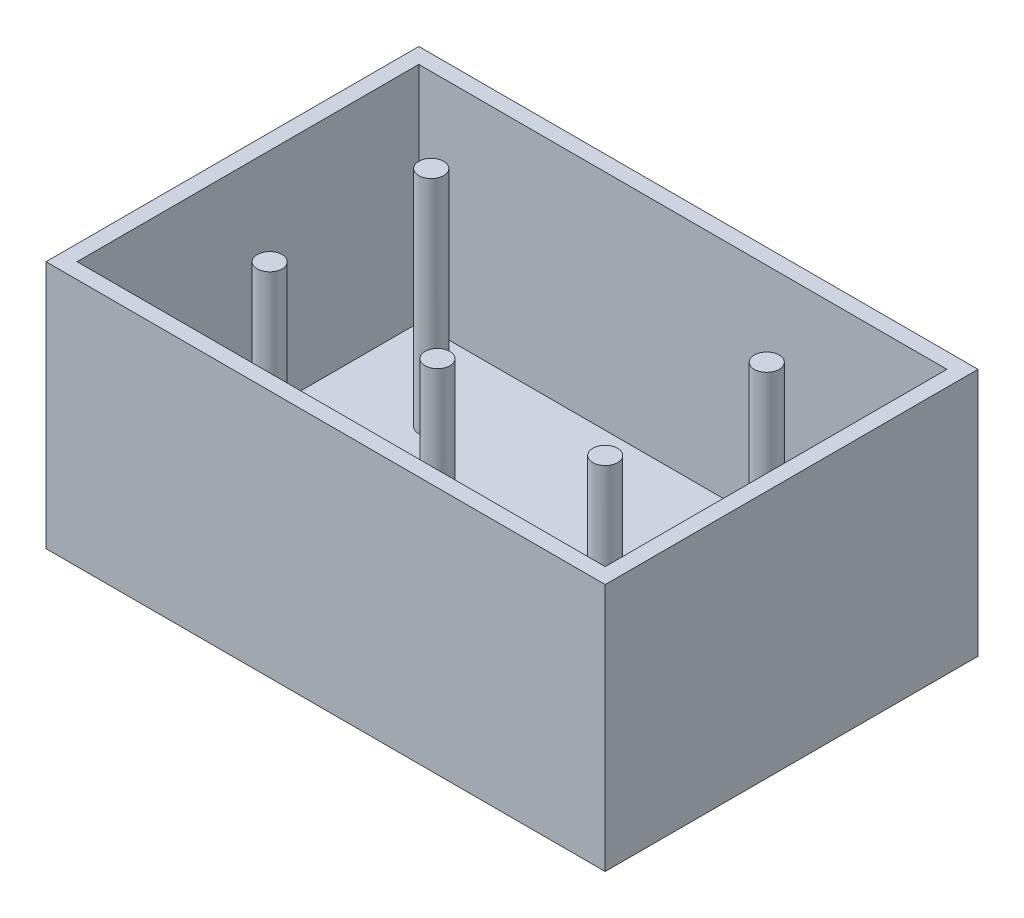
from build123d import *

# Parameters (mm, degrees)
SKETCH4_W           = 114.3
SKETCH4_H           = 76.2
BOSS_EXTRUDE2_DEPTH = 25.4
CUT_EXTRUDE1_REACH  = 47.72
SKETCH5_W           = 107.95
SKETCH5_H           = 69.85
SKETCH6_R           = 2.54
BOSS_EXTRUDE3_DEPTH = 25.4


with BuildPart() as part:
    # Sketch4 → Boss-Extrude2 (new body, symmetric)
    with BuildSketch(Plane(origin=(0, 0, 0), x_dir=(1, 0, 0), z_dir=(0, 1, 0))):
        Rectangle(SKETCH4_W, SKETCH4_H)
    extrude(amount=BOSS_EXTRUDE2_DEPTH, both=True)

    # Sketch5 → Cut-Extrude1 (cut, up to next)
    with BuildSketch(Plane(origin=(0, -20.32, 0), x_dir=(-1, 0, 0), z_dir=(0, -1, 0)), mode=Mode.PRIVATE) as cut_extrude1_sk1:
        Rectangle(SKETCH5_W, SKETCH5_H)
    cut_extrude1_tool1 = extrude(cut_extrude1_sk1.sketch, amount=-CUT_EXTRUDE1_REACH, mode=Mode.PRIVATE) & part.part
    add(cut_extrude1_tool1.solids().sort_by_distance((0, -20.32, 0))[0], mode=Mode.SUBTRACT)

    # Sketch6 → Boss-Extrude3 (add, symmetric)
    with BuildSketch(Plane(origin=(0, 0, 0), x_dir=(1, 0, 0), z_dir=(0, 1, 0))):
        with Locations((34.29, 17.78)):
            Circle(SKETCH6_R)
        with Locations((34.29, -15.24)):
            Circle(SKETCH6_R)
        with Locations((0, -15.24)):
            Circle(SKETCH6_R)
        with Locations((-34.29, -15.24)):
            Circle(SKETCH6_R)
        with Locations((-34.29, 17.78)):
            Circle(SKETCH6_R)
    extrude(amount=BOSS_EXTRUDE3_DEPTH, both=True)


solid = part.part
